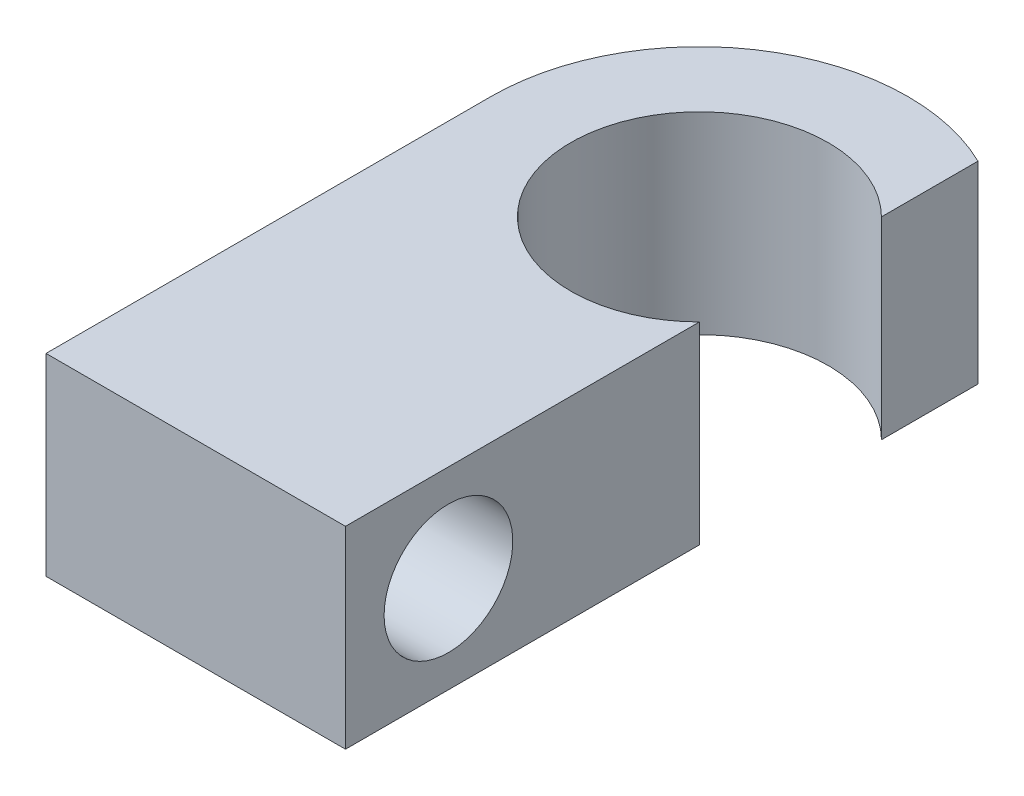
from build123d import *

# Parameters (mm, degrees)
BOSS_EXTRUDE1_DEPTH = 9.525
BOSS_EXTRUDE2_DEPTH = 9.525
SKETCH3_R           = 3.175
CUT_EXTRUDE1_DEPTH  = 15.774697863


with BuildPart() as part:
    # Sketch1 → Boss-Extrude1 (new body)
    with BuildSketch(Plane(origin=(0, 0, 0), x_dir=(1, 0, 0), z_dir=(0, 1, 0))):
        with BuildLine():
            Line((4.490128061, 4.490128061), (4.490128061, 9.252628061))
            ThreePointArc((4.490128061, 9.252628061), (-10.284569803, 0), (4.490128061, -9.252628061))
            Line((4.490128061, -9.252628061), (4.490128061, -4.490128061))
            ThreePointArc((4.490128061, -4.490128061), (-6.35, 0), (4.490128061, 4.490128061))
        make_face()
    extrude(amount=BOSS_EXTRUDE1_DEPTH)

    # Sketch2 → Boss-Extrude2 (add, through all)
    with BuildSketch(Plane(origin=(0, 9.525, 0), x_dir=(1, 0, 0), z_dir=(0, 1, 0))):
        with BuildLine():
            Line((-10.284569803, 0), (-10.284569803, -21.952628061))
            Line((-10.284569803, -21.952628061), (4.490128061, -21.952628061))
            Line((4.490128061, -21.952628061), (4.490128061, -9.252628061))
            ThreePointArc((4.490128061, -9.252628061), (-5.458632639, -8.716404405), (-10.284569803, 0))
        make_face()
    extrude(amount=-BOSS_EXTRUDE2_DEPTH)

    # Sketch3 → Cut-Extrude1 (cut, through all)
    with BuildSketch(Plane.ZY.offset(10.284569803)):
        with Locations((16.872628061, 4.7625)):
            Circle(SKETCH3_R)
    extrude(amount=-CUT_EXTRUDE1_DEPTH, mode=Mode.SUBTRACT)


solid = part.part
